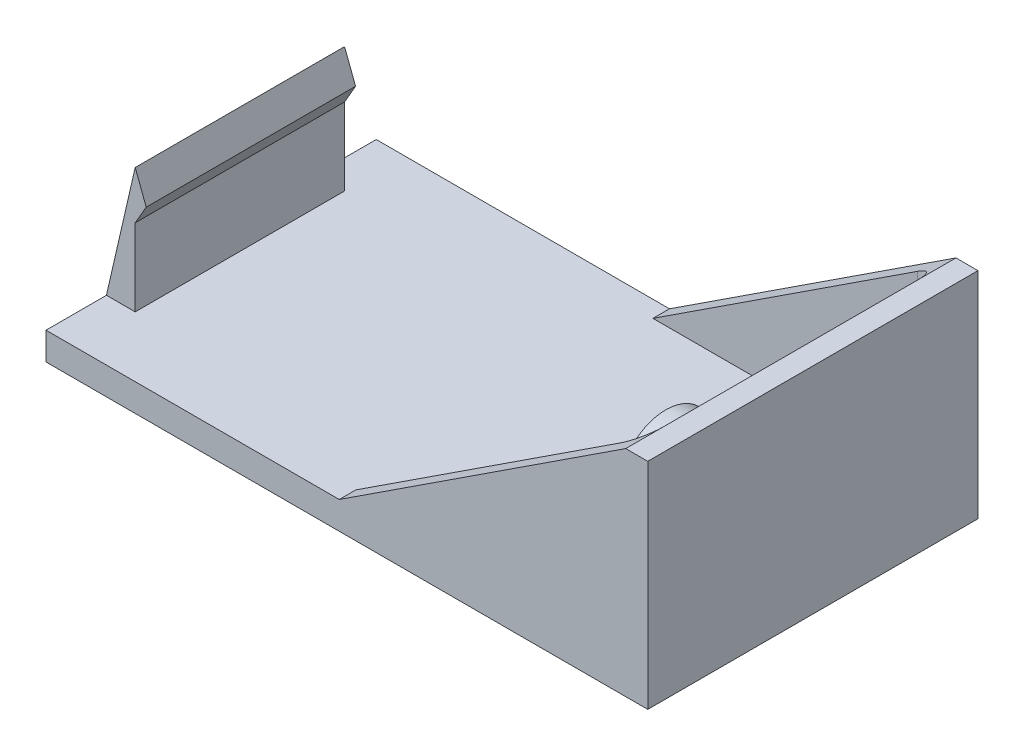
from build123d import *

# Parameters (mm, degrees)
SKETCH_1_W           = 54.61
SKETCH_1_H           = 29.97
EXTRUDE_1_DEPTH      = 2.5
EXTRUDE_2_DEPTH      = 17
CUT_EXTRUDE_1_DEPTH  = 30.97
EXTRUDE_4_DEPTH      = 9.5
EXTRUDE_4_DEPTH_BACK = 9.5
SKETCH_10_R          = 3.75
EXTRUDE_6_DEPTH      = 1
SKETCH_11_R          = 3
SKETCH_11_R_2        = 2
EXTRUDE_7_DEPTH      = 4
SKETCH_12_R          = 4.25
SKETCH_12_R_2        = 3.25
EXTRUDE_8_DEPTH      = 4


with BuildPart() as part:
    # Эскиз1 → Бобышка-Вытянуть1 (new body)
    with BuildSketch(Plane(origin=(0, 0, 0), x_dir=(1, 0, 0), z_dir=(0, 1, 0))):
        Rectangle(SKETCH_1_W, SKETCH_1_H)
    extrude(amount=EXTRUDE_1_DEPTH)

    # Эскиз2 → Бобышка-Вытянуть2 (add)
    with BuildSketch(Plane(origin=(0, 2.5, 0), x_dir=(1, 0, 0), z_dir=(0, 1, 0))):
        with BuildLine():
            Line((27.305, -14.985), (-0.695, -14.985))
            Line((-0.695, -14.985), (-0.695, -13.485))
            Line((-0.695, -13.485), (23.305, -13.485))
            ThreePointArc((23.305, -13.485), (24.719213562, -12.899213562), (25.305, -11.485))
            Line((25.305, -11.485), (25.305, 11.485))
            ThreePointArc((25.305, 11.485), (24.719213562, 12.899213562), (23.305, 13.485))
            Line((23.305, 13.485), (-0.695, 13.485))
            Line((-0.695, 13.485), (-0.695, 14.985))
            Line((-0.695, 14.985), (27.305, 14.985))
            Line((27.305, 14.985), (27.305, -14.985))
        make_face()
    extrude(amount=EXTRUDE_2_DEPTH)

    # Эскиз3 → Вырез-Вытянуть1 (cut, through all)
    with BuildSketch(Plane.XY.offset(14.985)):
        Polygon((-0.695, 2.5), (25.305, 19.5), (-0.695, 19.5), align=None)
    extrude(amount=-CUT_EXTRUDE_1_DEPTH, mode=Mode.SUBTRACT)

    # Эскиз8 → Бобышка-Вытянуть4 (add, two sides)
    with BuildSketch(Plane.XY) as extrude_4_sk:
        Polygon((-27.305, 2.5), (-24.695, 13.85), (-23.695, 11.232050808), (-24.695, 9.5), (-24.695, 2.5), align=None)
    extrude(amount=EXTRUDE_4_DEPTH)
    extrude(extrude_4_sk.sketch, amount=-EXTRUDE_4_DEPTH_BACK)

    # Эскиз10 → Бобышка-Вытянуть6 (add)
    with BuildSketch(Plane.ZY.offset(-25.305)):
        with Locations((-6.35, 11.48)):
            Circle(SKETCH_10_R)
        with Locations((6.35, 11.48)):
            Circle(SKETCH_10_R)
    extrude(amount=EXTRUDE_6_DEPTH)

    # Эскиз11 → Бобышка-Вытянуть7 (add)
    with BuildSketch(Plane.ZY.offset(-24.305)):
        with Locations((-6.35, 11.48)):
            Circle(SKETCH_11_R)
        with Locations((-6.35, 11.48)):
            Circle(SKETCH_11_R_2, mode=Mode.SUBTRACT)
    extrude(amount=EXTRUDE_7_DEPTH)

    # Эскиз12 → Бобышка-Вытянуть8 (add)
    with BuildSketch(Plane.ZY.offset(-24.305)):
        with Locations((6.35, 11.48)):
            Circle(SKETCH_12_R)
        with Locations((6.35, 11.48)):
            Circle(SKETCH_12_R_2, mode=Mode.SUBTRACT)
    extrude(amount=EXTRUDE_8_DEPTH)


solid = part.part
